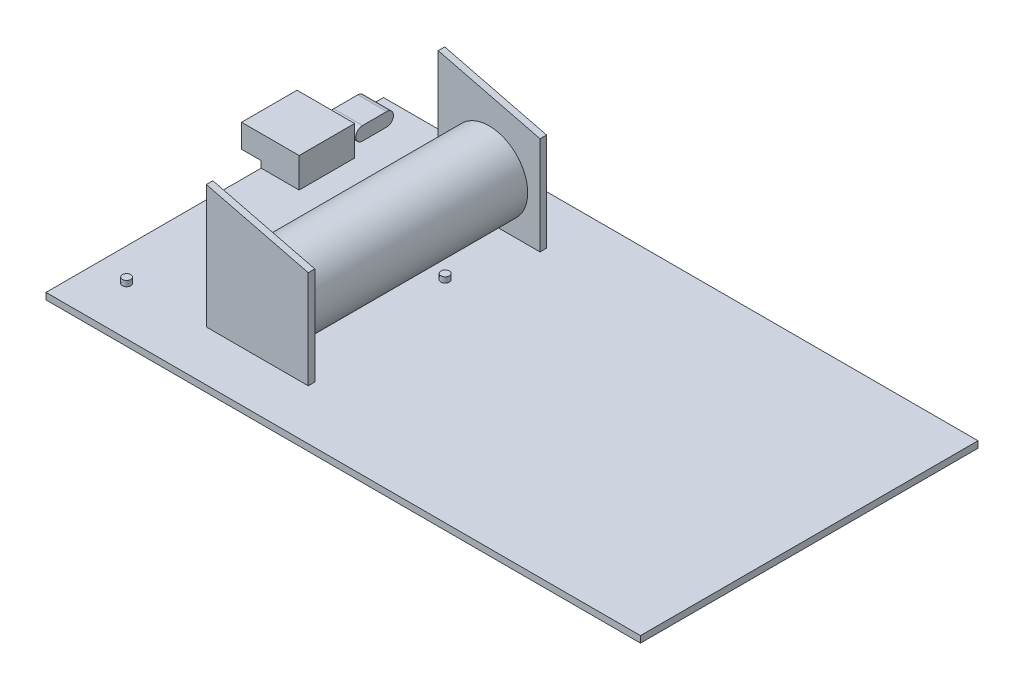
from build123d import *

# Parameters (mm, degrees)
SKETCH1_W                = 140.9
SKETCH1_H                = 80
PCB_DEPTH                = 1.55
BODYC_DEPTH              = 0.4
BODYC_DEPTH_BACK         = 6.45
SKETCH4_W                = 13.65
SKETCH4_H                = 13.15
BOSS_EXTRUDE4_DEPTH      = 7.1
BOSS_EXTRUDE4_DEPTH_BACK = 1.55
SKETCH5_W                = 4.65
SKETCH5_H                = 3.1
CUT_EXTRUDE3_DEPTH       = 14.1
SKETCH11_W               = 24.15
SKETCH11_H               = 1.55
BOSS_EXTRUDE8_DEPTH      = 29.25
SKETCH7_W                = 24.15
SKETCH7_H                = 1.55
BOSS_EXTRUDE5_DEPTH      = 29.25
CUT_EXTRUDE4_DEPTH       = 89
SKETCH12_R               = 9.15
BATTERY_DEPTH            = 54
SKETCH13_R               = 1
BUTTON_DEPTH             = 1.3
SKETCH14_R               = 1
RESET_DEPTH              = 1.3


with BuildPart() as part:
    # Sketch1 → PCB (new body)
    with BuildSketch(Plane(origin=(0, 0, 0), x_dir=(1, 0, 0), z_dir=(0, 1, 0))):
        Rectangle(SKETCH1_W, SKETCH1_H)
    extrude(amount=PCB_DEPTH)

    # Sketch3 → bodyC (add, two sides)
    with BuildSketch(Plane.ZY.offset(70.45)) as bodyc_sk:
        with BuildLine():
            Line((-34.3, 4.75), (-28.56, 4.75))
            ThreePointArc((-28.56, 4.75), (-26.96, 3.15), (-28.56, 1.55))
            Line((-28.56, 1.55), (-34.3, 1.55))
            ThreePointArc((-34.3, 1.55), (-35.9, 3.15), (-34.3, 4.75))
        make_face()
    extrude(amount=BODYC_DEPTH)
    extrude(bodyc_sk.sketch, amount=-BODYC_DEPTH_BACK)

    # Sketch4 → Boss-Extrude4 (add, two sides)
    with BuildSketch(Plane(origin=(0, 1.55, 0), x_dir=(1, 0, 0), z_dir=(0, 1, 0))) as boss_extrude4_sk:
        with Locations((-68.275, 17.575)):
            Rectangle(SKETCH4_W, SKETCH4_H)
    extrude(amount=BOSS_EXTRUDE4_DEPTH)
    extrude(boss_extrude4_sk.sketch, amount=-BOSS_EXTRUDE4_DEPTH_BACK)

    # Sketch5 → Cut-Extrude3 (cut)
    with BuildSketch(Plane.XY.offset(-11)):
        with Locations((-72.775, 1.55)):
            Rectangle(SKETCH5_W, SKETCH5_H)
    extrude(amount=-CUT_EXTRUDE3_DEPTH, mode=Mode.SUBTRACT)

    # Sketch11 → Boss-Extrude8 (add)
    with BuildSketch(Plane(origin=(0, 1.55, 0), x_dir=(1, 0, 0), z_dir=(0, 1, 0))):
        with Locations((-32.275, 27.625)):
            Rectangle(SKETCH11_W, SKETCH11_H)
    extrude(amount=BOSS_EXTRUDE8_DEPTH)

    # Sketch7 → Boss-Extrude5 (add)
    with BuildSketch(Plane(origin=(0, 1.55, 0), x_dir=(1, 0, 0), z_dir=(0, 1, 0))):
        with Locations((-32.275, -27.325)):
            Rectangle(SKETCH7_W, SKETCH7_H)
    extrude(amount=BOSS_EXTRUDE5_DEPTH)

    # Sketch8 → Cut-Extrude4 (cut)
    with BuildSketch(Plane.XY.offset(28.1)):
        Polygon((-44.35, 30.8), (-20.2, 24.778728731), (-20.2, 30.8), align=None)
    extrude(amount=-CUT_EXTRUDE4_DEPTH, mode=Mode.SUBTRACT)

    # Sketch12 → Battery (add)
    with BuildSketch(Plane.XY.offset(-26.85)):
        with Locations((-32.275, 12.25)):
            Circle(SKETCH12_R)
    extrude(amount=BATTERY_DEPTH)

    # Sketch13 → Button (add)
    with BuildSketch(Plane(origin=(0, 1.55, 0), x_dir=(1, 0, 0), z_dir=(0, 1, 0))):
        with Locations((-62.75, -28.6)):
            Circle(SKETCH13_R)
    extrude(amount=BUTTON_DEPTH)

    # Sketch14 → Reset (add)
    with BuildSketch(Plane(origin=(0, 1.55, 0), x_dir=(1, 0, 0), z_dir=(0, 1, 0))):
        with Locations((-25.75, 9.9)):
            Circle(SKETCH14_R)
    extrude(amount=RESET_DEPTH)


solid = part.part
